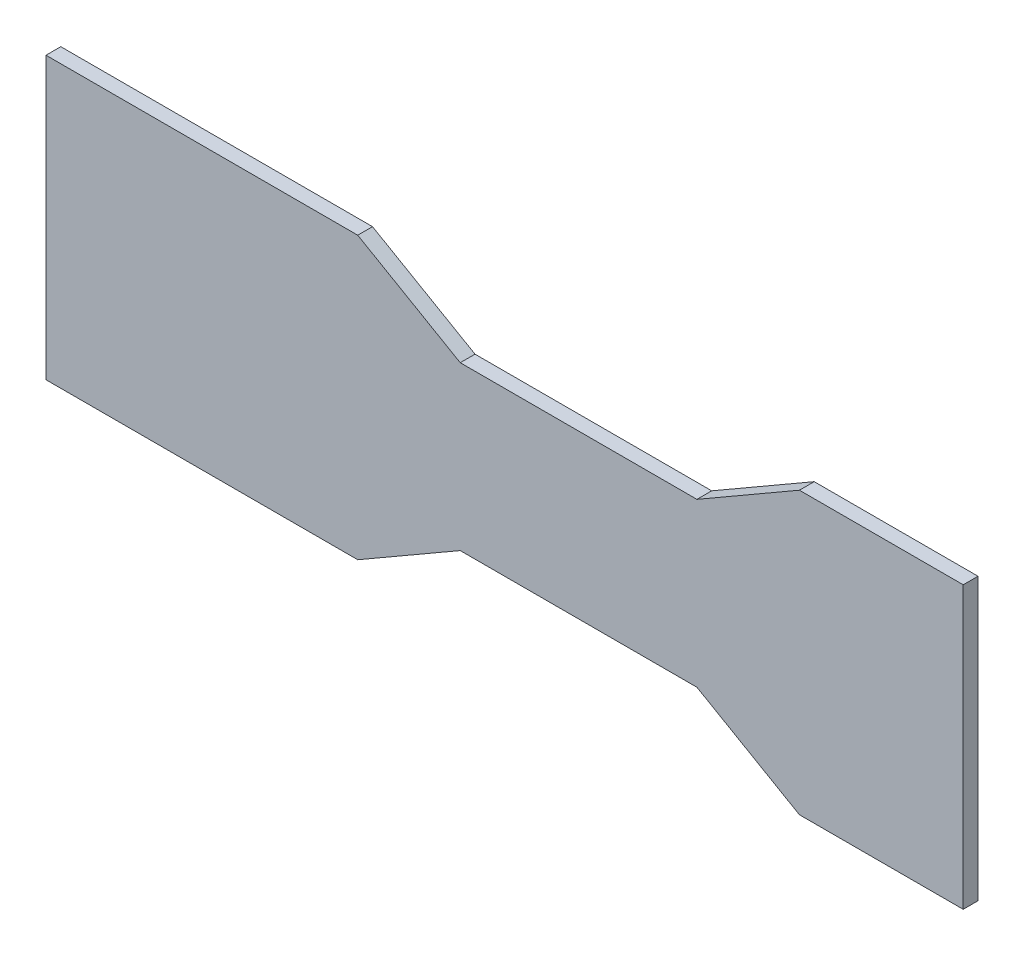
from build123d import *

# Parameters (mm, degrees)
SKETCH1_W           = 393.7
SKETCH1_H           = 120.65
BOSS_EXTRUDE1_DEPTH = 6.35
CUT_EXTRUDE1_DEPTH  = 7.35


with BuildPart() as part:
    # Sketch1 → Boss-Extrude1 (new body)
    with BuildSketch(Plane.XY):
        with Locations((196.85, 60.325)):
            Rectangle(SKETCH1_W, SKETCH1_H)
    extrude(amount=BOSS_EXTRUDE1_DEPTH)

    # Sketch2 → Cut-Extrude1 (cut, through all)
    with BuildSketch(Plane.XY.offset(6.35)):
        Polygon((133.805909488, 120.65), (177.8, 95.25), (279.4, 95.25), (323.394090512, 120.65), align=None)
        Polygon((133.805909488, 0), (177.8, 25.4), (279.4, 25.4), (323.394090512, 0), align=None)
    extrude(amount=-CUT_EXTRUDE1_DEPTH, mode=Mode.SUBTRACT)


solid = part.part
